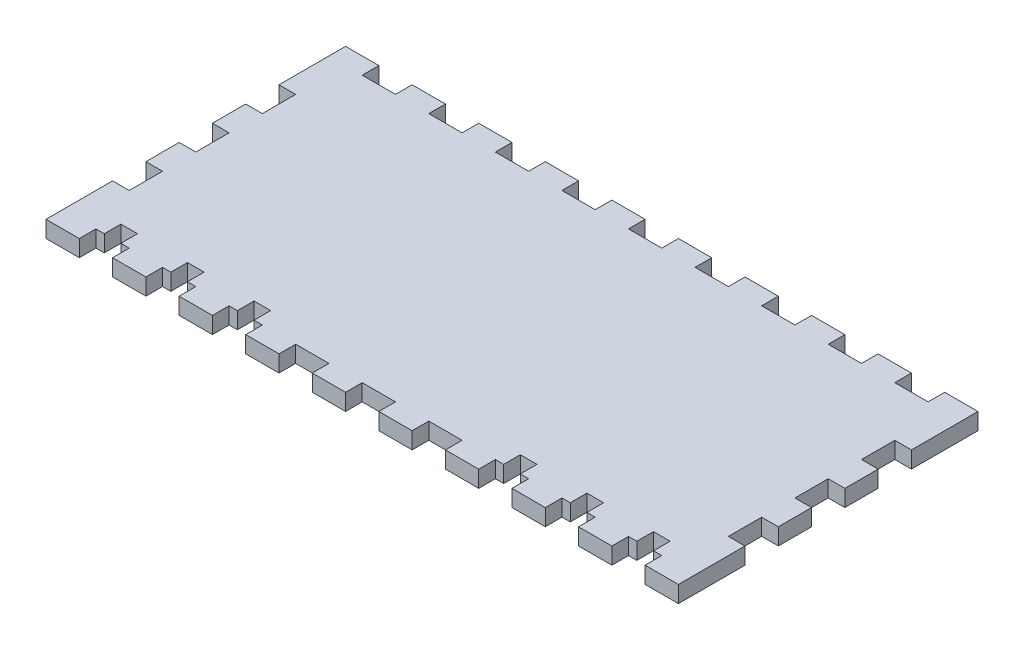
from build123d import *

# Parameters (mm, degrees)
SKETCH1_W           = 241.3
SKETCH1_H           = 114.3
BOSS_EXTRUDE1_DEPTH = 6.35
SKETCH2_W           = 12.7
SKETCH2_H           = 6.35
CUT_EXTRUDE1_DEPTH  = 7.35
SKETCH3_W           = 6.35
SKETCH3_H           = 12.7
CUT_EXTRUDE2_DEPTH  = 7.35
LPATTERN1_COUNT     = 2
LPATTERN1_PITCH     = 25.4
LPATTERN1_COL_COUNT = 2
LPATTERN1_COL_PITCH = 25.4
SKETCH4_W           = 6.35
SKETCH4_H           = 6.35
CUT_EXTRUDE3_DEPTH  = 7.35
LPATTERN2_COUNT     = 9
LPATTERN2_PITCH     = 25.4


with BuildPart() as part:
    # Sketch1 → Boss-Extrude1 (new body)
    with BuildSketch(Plane(origin=(0, 0, 0), x_dir=(1, 0, 0), z_dir=(0, 1, 0))):
        with Locations((120.65, 57.15)):
            Rectangle(SKETCH1_W, SKETCH1_H)
    extrude(amount=BOSS_EXTRUDE1_DEPTH)

    # Sketch2 → Cut-Extrude1 (cut, through all)
    with BuildSketch(Plane(origin=(0, 6.35, 0), x_dir=(1, 0, 0), z_dir=(0, 1, 0))):
        with Locations((19.05, 111.125)):
            Rectangle(SKETCH2_W, SKETCH2_H)
        with Locations((-6.35, 111.125)):
            Rectangle(SKETCH2_W, SKETCH2_H)
        with Locations((-6.35, 3.175)):
            Rectangle(SKETCH2_W, SKETCH2_H)
        with Locations((19.05, 3.175)):
            Rectangle(SKETCH2_W, SKETCH2_H)
        with Locations((44.45, 111.125)):
            Rectangle(SKETCH2_W, SKETCH2_H)
        with Locations((44.45, 3.175)):
            Rectangle(SKETCH2_W, SKETCH2_H)
        with Locations((69.85, 111.125)):
            Rectangle(SKETCH2_W, SKETCH2_H)
        with Locations((69.85, 3.175)):
            Rectangle(SKETCH2_W, SKETCH2_H)
        with Locations((95.25, 111.125)):
            Rectangle(SKETCH2_W, SKETCH2_H)
        with Locations((95.25, 3.175)):
            Rectangle(SKETCH2_W, SKETCH2_H)
        with Locations((120.65, 111.125)):
            Rectangle(SKETCH2_W, SKETCH2_H)
        with Locations((120.65, 3.175)):
            Rectangle(SKETCH2_W, SKETCH2_H)
        with Locations((146.05, 111.125)):
            Rectangle(SKETCH2_W, SKETCH2_H)
        with Locations((146.05, 3.175)):
            Rectangle(SKETCH2_W, SKETCH2_H)
        with Locations((171.45, 111.125)):
            Rectangle(SKETCH2_W, SKETCH2_H)
        with Locations((171.45, 3.175)):
            Rectangle(SKETCH2_W, SKETCH2_H)
        with Locations((196.85, 111.125)):
            Rectangle(SKETCH2_W, SKETCH2_H)
        with Locations((196.85, 3.175)):
            Rectangle(SKETCH2_W, SKETCH2_H)
        with Locations((222.25, 111.125)):
            Rectangle(SKETCH2_W, SKETCH2_H)
        with Locations((222.25, 3.175)):
            Rectangle(SKETCH2_W, SKETCH2_H)
    extrude(amount=-CUT_EXTRUDE1_DEPTH, mode=Mode.SUBTRACT)

    # Sketch3 → Cut-Extrude2 (cut, through all)
    with BuildSketch(Plane(origin=(0, 6.35, 0), x_dir=(1, 0, 0), z_dir=(0, 1, 0))):
        with Locations((3.175, 57.15)):
            Rectangle(SKETCH3_W, SKETCH3_H)
        with Locations((238.125, 57.15)):
            Rectangle(SKETCH3_W, SKETCH3_H)
    cut_extrude2 = extrude(amount=-CUT_EXTRUDE2_DEPTH, mode=Mode.SUBTRACT)

    # LPattern1: Cut-Extrude2 ×2
    with Locations(*[(0, 0, i * LPATTERN1_PITCH) for i in range(1, LPATTERN1_COUNT)]):
        add(cut_extrude2, mode=Mode.SUBTRACT)

    # LPattern1 col: Cut-Extrude2 ×2
    with Locations(*[(0, 0, -i * LPATTERN1_COL_PITCH) for i in range(1, LPATTERN1_COL_COUNT)]):
        add(cut_extrude2, mode=Mode.SUBTRACT)

    # Sketch4 → Cut-Extrude3 (cut, through all)
    with BuildSketch(Plane(origin=(0, 6.35, 0), x_dir=(1, 0, 0), z_dir=(0, 1, 0))):
        with Locations((19.05, 9.525)):
            Rectangle(SKETCH4_W, SKETCH4_H)
    cut_extrude3 = extrude(amount=-CUT_EXTRUDE3_DEPTH, mode=Mode.SUBTRACT)

    # LPattern2: Cut-Extrude3 ×9, 3 skipped
    with Locations(*[(i * LPATTERN2_PITCH, 0, 0) for i in range(1, LPATTERN2_COUNT) if i not in (3, 4, 5)]):
        add(cut_extrude3, mode=Mode.SUBTRACT)


solid = part.part
